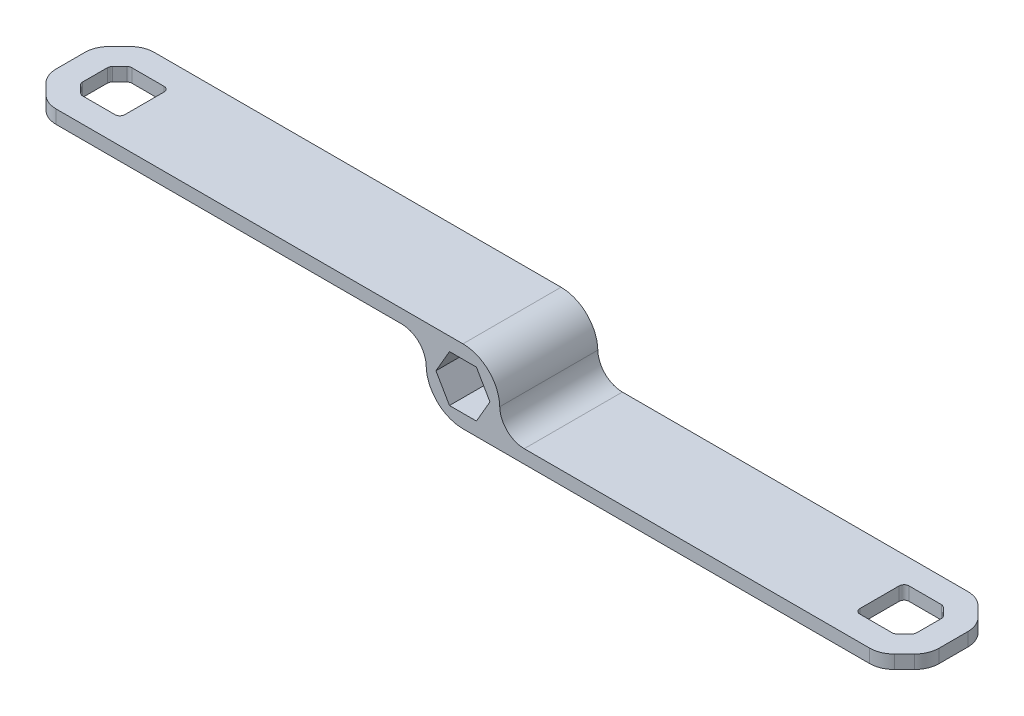
from build123d import *

# Parameters (mm, degrees)
SKETCH2_R           = 7.5
BOSS_EXTRUDE1_DEPTH = 20
SKETCH3_W           = 20
SKETCH3_H           = 2.7375
BOSS_EXTRUDE2_DEPTH = 90
FILLET1_R           = 5
CHAMFER1_SIZE       = 5
FILLET2_R           = 5
CUT_EXTRUDE1_DEPTH  = 45
FILLET3_R           = 1
SKETCH5_W           = 20
SKETCH5_H           = 2.7375
BOSS_EXTRUDE3_DEPTH = 90
CHAMFER2_SIZE       = 5
FILLET4_R           = 5
FILLET5_R           = 5
CUT_EXTRUDE2_DEPTH  = 90
FILLET6_R           = 1


with BuildPart() as part:
    # Sketch2 → Boss-Extrude1 (new body)
    with BuildSketch(Plane.XY):
        Circle(SKETCH2_R)
        Polygon((5.499261314, 0), (2.749630657, 4.7625), (-2.749630657, 4.7625), (-5.499261314, 0), (-2.749630657, -4.7625), (2.749630657, -4.7625), align=None, mode=Mode.SUBTRACT)
    extrude(amount=BOSS_EXTRUDE1_DEPTH)

    # Sketch3 → Boss-Extrude2 (add)
    with BuildSketch(Plane.ZY):
        with Locations((10, 6.13125)):
            Rectangle(SKETCH3_W, SKETCH3_H)
    extrude(amount=BOSS_EXTRUDE2_DEPTH)

    # Fillet1
    fillet1_edges = [part.edges().sort_by_distance(p)[0] for p in [
        (-5.793841019, 4.7625, 10),
    ]]
    fillet(fillet1_edges, radius=FILLET1_R)

    # Chamfer1
    chamfer1_edges = [part.edges().sort_by_distance(p)[0] for p in [
        (-90, 6.13125, 0),
        (-90, 6.13125, 20),
    ]]
    chamfer(chamfer1_edges, length=CHAMFER1_SIZE)

    # Fillet2
    fillet2_edges = [part.edges().sort_by_distance(p)[0] for p in [
        (-90, 6.13125, 15),
        (-90, 6.13125, 5),
        (-85, 6.13125, 0),
        (-85, 6.13125, 20),
    ]]
    fillet(fillet2_edges, radius=FILLET2_R)

    # Sketch4 → Cut-Extrude1 (cut)
    with BuildSketch(Plane(origin=(0, 7.5, 0), x_dir=(1, 0, 0), z_dir=(0, 1, 0))):
        Polygon((-74.928932188, -15), (-74.928932188, -5), (-82.928932188, -5), (-85, -7.071067812), (-85, -12.928932188), (-82.928932188, -15), align=None)
    extrude(amount=-CUT_EXTRUDE1_DEPTH, mode=Mode.SUBTRACT)

    # Fillet3
    fillet3_edges = [part.edges().sort_by_distance(p)[0] for p in [
        (-74.928932188, 6.13125, 15),
        (-82.928932188, 6.13125, 15),
        (-85, 6.13125, 12.928932188),
        (-85, 6.13125, 7.071067812),
        (-82.928932188, 6.13125, 5),
        (-74.928932188, 6.13125, 5),
    ]]
    fillet(fillet3_edges, radius=FILLET3_R)

    # Sketch5 → Boss-Extrude3 (add)
    with BuildSketch(Plane.ZY):
        with Locations((10, -6.13125)):
            Rectangle(SKETCH5_W, SKETCH5_H)
    extrude(amount=-BOSS_EXTRUDE3_DEPTH)

    # Chamfer2
    chamfer2_edges = [part.edges().sort_by_distance(p)[0] for p in [
        (90, -6.13125, 20),
        (90, -6.13125, 0),
    ]]
    chamfer(chamfer2_edges, length=CHAMFER2_SIZE)

    # Fillet4
    fillet4_edges = [part.edges().sort_by_distance(p)[0] for p in [
        (85, -6.13125, 20),
        (90, -6.13125, 5),
        (90, -6.13125, 15),
        (85, -6.13125, 0),
    ]]
    fillet(fillet4_edges, radius=FILLET4_R)

    # Fillet5
    fillet5_edges = [part.edges().sort_by_distance(p)[0] for p in [
        (5.793841019, -4.7625, 10),
    ]]
    fillet(fillet5_edges, radius=FILLET5_R)

    # Sketch7 → Cut-Extrude2 (cut)
    with BuildSketch(Plane.XZ.offset(7.5)):
        Polygon((74.928932188, 5), (74.928932188, 15), (82.928932188, 15), (85, 12.928932188), (85, 7.071067812), (82.928932188, 5), align=None)
    extrude(amount=-CUT_EXTRUDE2_DEPTH, mode=Mode.SUBTRACT)

    # Fillet6
    fillet6_edges = [part.edges().sort_by_distance(p)[0] for p in [
        (82.928932188, -6.13125, 5),
        (74.928932188, -6.13125, 5),
        (74.928932188, -6.13125, 15),
        (82.928932188, -6.13125, 15),
        (85, -6.13125, 12.928932188),
        (85, -6.13125, 7.071067812),
    ]]
    fillet(fillet6_edges, radius=FILLET6_R)


solid = part.part
